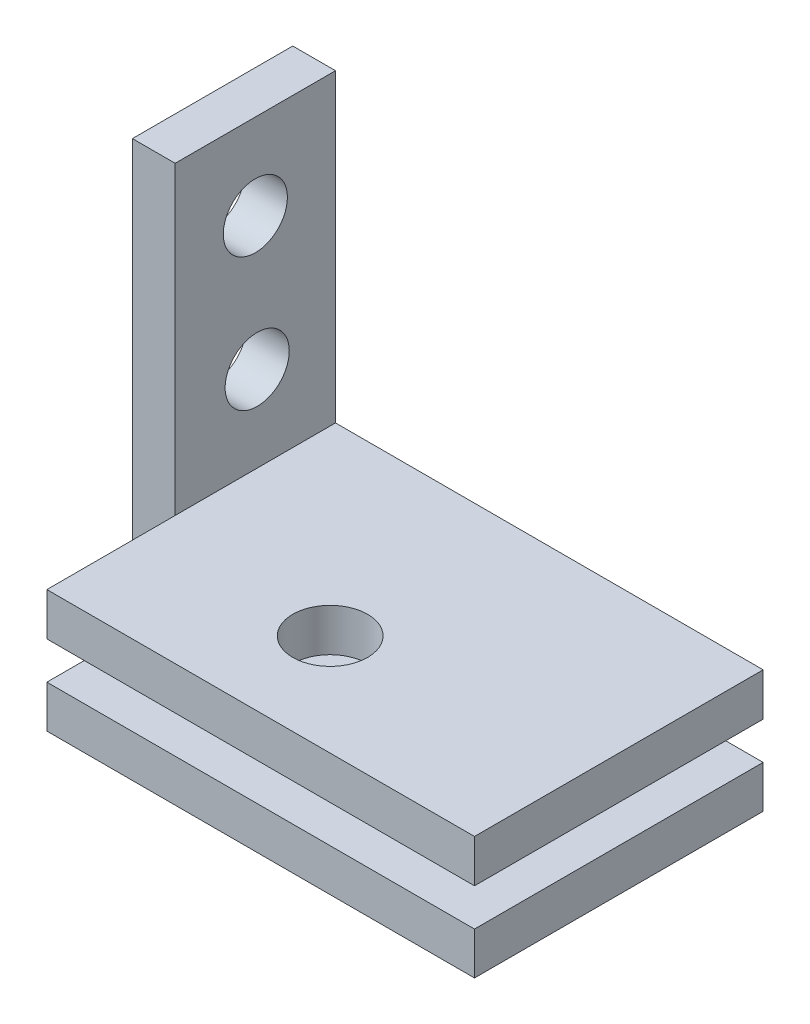
from build123d import *

# Parameters (mm, degrees)
SKETCH1_W           = 7.5
SKETCH1_H           = 20
BOSS_EXTRUDE2_DEPTH = 2
SKETCH2_W           = 7.5
SKETCH2_H           = 1.98347932
BOSS_EXTRUDE3_DEPTH = 20
SKETCH3_W           = 7.5
SKETCH3_H           = 2
BOSS_EXTRUDE4_DEPTH = 20
SKETCH5_R           = 1.5
CUT_EXTRUDE1_DEPTH  = 20
SKETCH8_W           = 20
SKETCH8_H           = 2
BOSS_EXTRUDE6_DEPTH = 6
SKETCH9_W           = 20
SKETCH9_H           = 1.98347932
BOSS_EXTRUDE7_DEPTH = 6
SKETCH10_R          = 1.75
CUT_EXTRUDE2_DEPTH  = 6


with BuildPart() as part:
    # Sketch1 → Boss-Extrude2 (new body)
    with BuildSketch(Plane(origin=(0, 0, 0), x_dir=(0, 0, -1), z_dir=(1, 0, 0))):
        with Locations((3.009581882, -0.975609756)):
            Rectangle(SKETCH1_W, SKETCH1_H)
    extrude(amount=BOSS_EXTRUDE2_DEPTH)

    # Sketch2 → Boss-Extrude3 (add)
    with BuildSketch(Plane(origin=(2, 0, 0), x_dir=(0, 0, -1), z_dir=(1, 0, 0))):
        with Locations((3.009581882, -9.983870096)):
            Rectangle(SKETCH2_W, SKETCH2_H)
    extrude(amount=BOSS_EXTRUDE3_DEPTH)

    # Sketch3 → Boss-Extrude4 (add)
    with BuildSketch(Plane(origin=(2, 0, 0), x_dir=(0, 0, -1), z_dir=(1, 0, 0))):
        with Locations((3.009581882, -6.242130436)):
            Rectangle(SKETCH3_W, SKETCH3_H)
    extrude(amount=BOSS_EXTRUDE4_DEPTH)

    # Sketch5 → Cut-Extrude1 (cut)
    with BuildSketch(Plane(origin=(2, 0, 0), x_dir=(0, 0, -1), z_dir=(1, 0, 0))):
        with Locations((3.009581882, 5.024390244)):
            Circle(SKETCH5_R)
        with Locations((3.096458319, -1.242130436)):
            Circle(SKETCH5_R)
    extrude(amount=-CUT_EXTRUDE1_DEPTH, mode=Mode.SUBTRACT)

    # Sketch8 → Boss-Extrude6 (add)
    with BuildSketch(Plane.XY.offset(0.740418118)):
        with Locations((12, -6.242130436)):
            Rectangle(SKETCH8_W, SKETCH8_H)
    extrude(amount=BOSS_EXTRUDE6_DEPTH)

    # Sketch9 → Boss-Extrude7 (add)
    with BuildSketch(Plane.XY.offset(0.740418118)):
        with Locations((12, -9.983870096)):
            Rectangle(SKETCH9_W, SKETCH9_H)
    extrude(amount=BOSS_EXTRUDE7_DEPTH)

    # Sketch10 → Cut-Extrude2 (cut)
    with BuildSketch(Plane(origin=(0, -5.242130436, 0), x_dir=(1, 0, 0), z_dir=(0, 1, 0))):
        with Locations((10.5, -1.990418118)):
            Circle(SKETCH10_R)
    extrude(amount=-CUT_EXTRUDE2_DEPTH, mode=Mode.SUBTRACT)


solid = part.part
